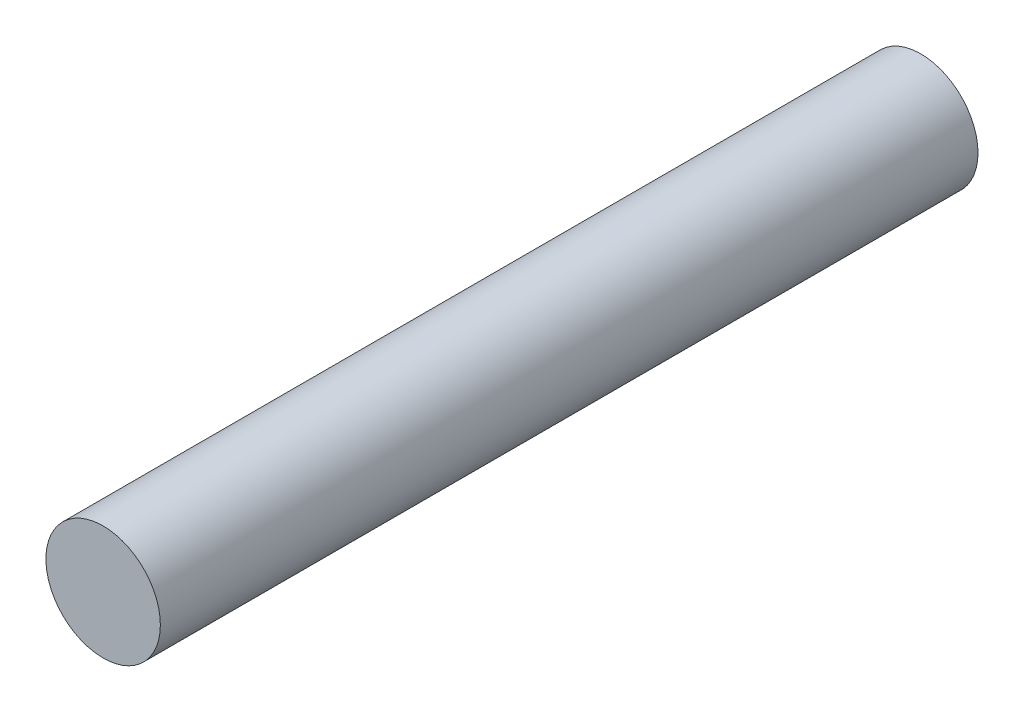
from build123d import *

# Parameters (mm, degrees)
SKETCH1_R           = 3.5
BOSS_EXTRUDE1_DEPTH = 50


with BuildPart() as part:
    # Sketch1 → Boss-Extrude1 (new body)
    with BuildSketch(Plane.XY):
        Circle(SKETCH1_R)
    extrude(amount=BOSS_EXTRUDE1_DEPTH)


solid = part.part
